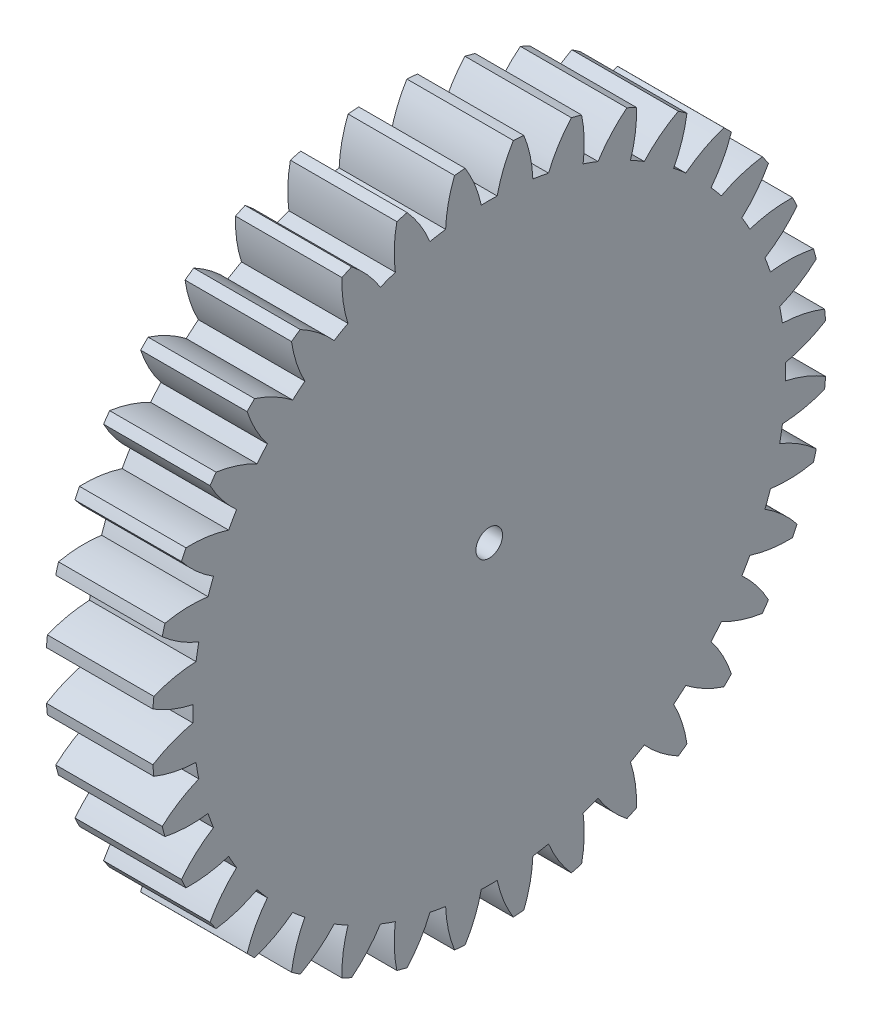
from build123d import *

# Parameters (mm, degrees)
BASPROSKE_W        = 3.175
BASPROSKE_H        = 10.054166667
TOOTHCUT_DEPTH     = 15.568910725
TEETHCUTS_COUNT    = 36
TEETHCUTS_ANGLE    = 350
BORSKE_R           = 0.396875
BORE_DEPTH         = 50.8000508
SKETCH7_R          = 2.778125
CUT_EXTRUDE2_DEPTH = 1.5875


with BuildPart() as part:
    # BasProSke → Base-Revolve (revolve)
    with BuildSketch(Plane(origin=(0, 0, 0), x_dir=(1, 0, 0), z_dir=(0, 1, 0)), mode=Mode.PRIVATE) as base_revolve_sk:
        with Locations((1.5875, 5.027083334)):
            Rectangle(BASPROSKE_W, BASPROSKE_H)
    revolve(base_revolve_sk.sketch.rotate(Axis((-10, 0, 0), (1, 0, 0)), 180), axis=Axis((-10, 0, 0), (1, 0, 0)))

    # TooCutSke → ToothCut (cut, through all)
    with BuildSketch(Plane(origin=(0, 0, 0), x_dir=(0, 0, -1), z_dir=(1, 0, 0))):
        with BuildLine():
            ThreePointArc((0.23736699, 8.836012311), (0, 8.8392), (-0.23736699, 8.836012311))
            ThreePointArc((-0.23736699, 8.836012311), (-0.432733953, 9.465982554), (-0.733821522, 10.052819016))
            ThreePointArc((-0.733821522, 10.052819016), (0, 10.079566667), (0.733821522, 10.052819016))
            ThreePointArc((0.733821522, 10.052819016), (0.432733953, 9.465982554), (0.23736699, 8.836012311))
        make_face()
    toothcut = extrude(amount=TOOTHCUT_DEPTH, mode=Mode.SUBTRACT)

    # TeethCuts: ToothCut ×36 about axis
    teethcuts_axis = Axis((-10, 0, 0), (1, 0, 0))
    for i in range(1, TEETHCUTS_COUNT):
        add(toothcut.rotate(teethcuts_axis, i * TEETHCUTS_ANGLE / (TEETHCUTS_COUNT - 1)), mode=Mode.SUBTRACT)

    # BorSke → Bore (cut, symmetric)
    with BuildSketch(Plane(origin=(0, 0, 0), x_dir=(0, 0, -1), z_dir=(1, 0, 0))):
        with Locations(Location((0, 0, 0), (0, 0, 180))):
            Circle(BORSKE_R)
    extrude(amount=BORE_DEPTH, both=True, mode=Mode.SUBTRACT)

    # Sketch7 → Cut-Extrude2 (cut)
    with BuildSketch(Plane.ZY):
        Circle(SKETCH7_R)
    extrude(amount=-CUT_EXTRUDE2_DEPTH, mode=Mode.SUBTRACT)


solid = part.part
